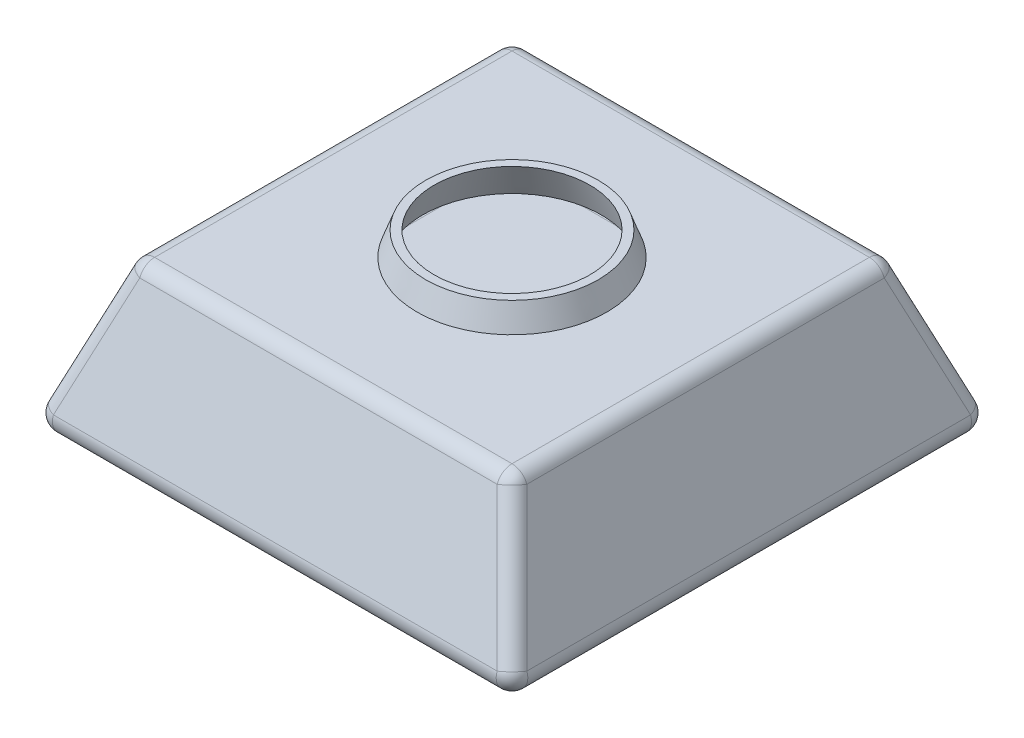
from build123d import *

# Parameters (mm, degrees)
SKETCH1_W           = 480
SKETCH1_H           = 480
BOSS_EXTRUDE1_DEPTH = 190
BOSS_EXTRUDE1_DRAFT = 20
FILLET1_R           = 20
SKETCH2_R           = 120
BOSS_EXTRUDE2_DEPTH = 30
BOSS_EXTRUDE2_TAPER = 20
SHELL1_T            = -10
SCALE1_SCALE        = 0.5


with BuildPart() as part:
    # Sketch1 → Boss-Extrude1 (with draft: the straight prism first)
    with BuildSketch(Plane(origin=(0, 0, 0), x_dir=(1, 0, 0), z_dir=(0, 1, 0))):
        with Locations((240, -240)):
            Rectangle(SKETCH1_W, SKETCH1_H)
    extrude(amount=-BOSS_EXTRUDE1_DEPTH)
    # Boss-Extrude1: the draft: its side faces are tilted about the plane it starts from
    boss_extrude1_sides = [part.faces().sort_by_distance(p)[0] for p in [
        (0, -95, 240),
        (240, -95, 480),
        (480, -95, 240),
        (240, -95, 0),
    ]]
    draft(boss_extrude1_sides, Plane(origin=(0, 0, 0), x_dir=(1, 0, 0), z_dir=(0, 1, 0)), BOSS_EXTRUDE1_DRAFT)

    # Fillet1
    fillet1_edges = [part.edges().sort_by_distance(p)[0] for p in [
        (549.154344511, -190, 240),
        (240, -190, -69.154344511),
        (-69.154344511, -190, 240),
        (240, 0, 0),
        (480, 0, 240),
        (240, 0, 480),
        (0, 0, 240),
        (-34.577172255, -95, -34.577172255),
        (514.577172255, -95, -34.577172255),
        (514.577172255, -95, 514.577172255),
        (-34.577172255, -95, 514.577172255),
        (240, -190, 549.154344511),
    ]]
    fillet(fillet1_edges, radius=FILLET1_R)

    # Sketch2 → Boss-Extrude2 (add)
    with BuildSketch(Plane(origin=(0, 0, 0), x_dir=(1, 0, 0), z_dir=(0, 1, 0))):
        with Locations((240, -240)):
            Circle(SKETCH2_R)
    extrude(amount=BOSS_EXTRUDE2_DEPTH, taper=BOSS_EXTRUDE2_TAPER)

    # Shell1
    shell1_openings = [part.faces().sort_by_distance(p)[0] for p in [
        (240, 30, 240),
    ]]
    offset(amount=SHELL1_T, openings=shell1_openings, kind=Kind.INTERSECTION)


with BuildPart() as part_1:
    # Scale1: scaled about (0, 0, 0)
    add(part.part.scale(SCALE1_SCALE))


solid = part_1.part
